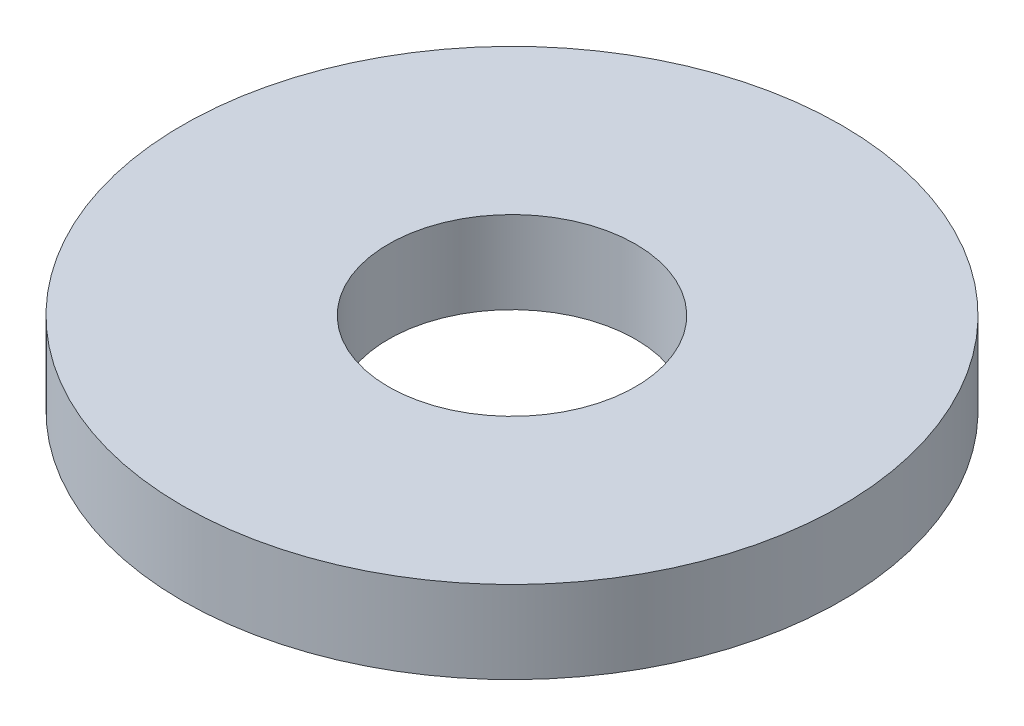
from build123d import *

# Parameters (mm, degrees)
SKETCH1_R           = 4
SKETCH1_R_2         = 1.5
BOSS_EXTRUDE1_DEPTH = 1


with BuildPart() as part:
    # Sketch1 → Boss-Extrude1 (new body)
    with BuildSketch(Plane(origin=(0, 0, 0), x_dir=(1, 0, 0), z_dir=(0, 1, 0))):
        Circle(SKETCH1_R)
        Circle(SKETCH1_R_2, mode=Mode.SUBTRACT)
    extrude(amount=BOSS_EXTRUDE1_DEPTH)


solid = part.part
